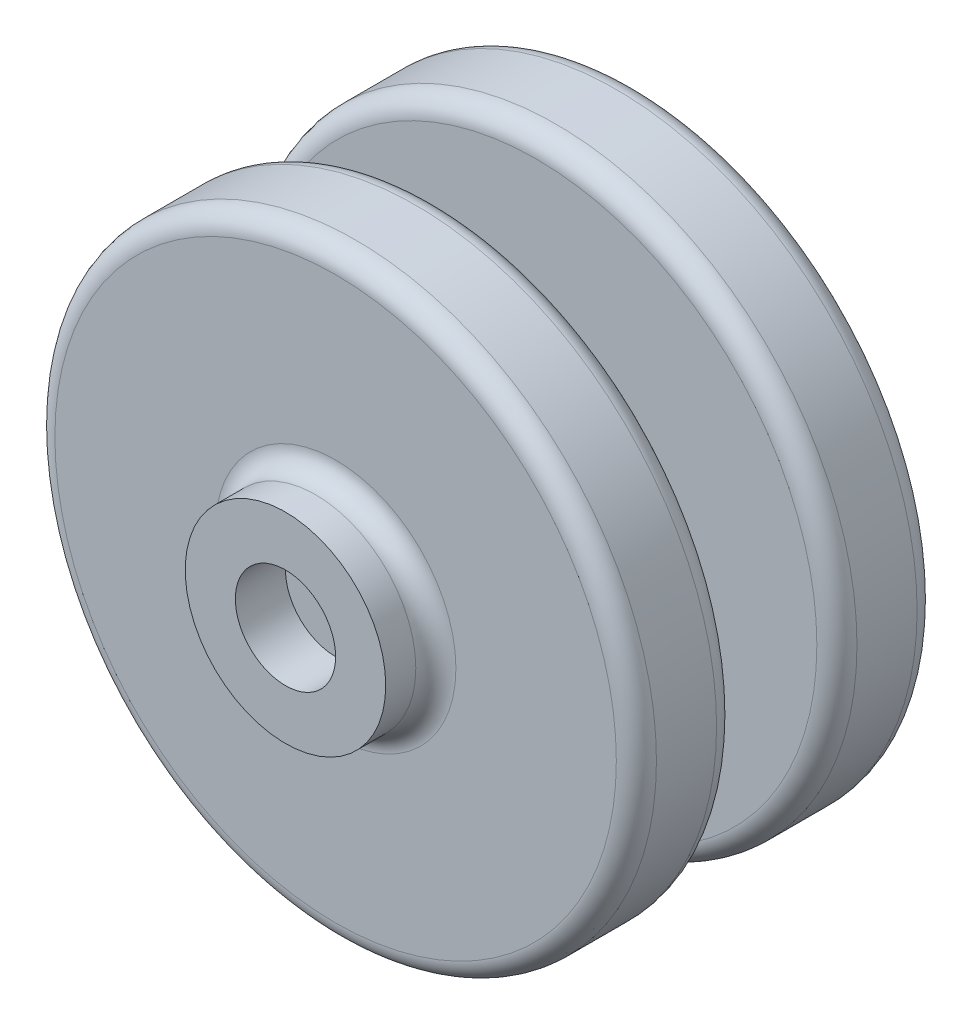
from build123d import *

# Parameters (mm, degrees)
SKETCH1_R           = 30
BOSS_EXTRUDE1_DEPTH = 10
SKETCH2_R           = 5
BOSS_EXTRUDE2_DEPTH = 10
SKETCH3_R           = 30
BOSS_EXTRUDE3_DEPTH = 10
SKETCH5_R           = 10
SKETCH5_R_2         = 5
BOSS_EXTRUDE5_DEPTH = 5
FILLET1_R           = 2
FILLET2_R           = 2


with BuildPart() as part:
    # Sketch1 → Boss-Extrude1 (new body)
    with BuildSketch(Plane.XY):
        Circle(SKETCH1_R)
    extrude(amount=BOSS_EXTRUDE1_DEPTH)

    # Sketch2 → Boss-Extrude2 (add)
    with BuildSketch(Plane.XY.offset(10)):
        Circle(SKETCH2_R)
    extrude(amount=BOSS_EXTRUDE2_DEPTH)

    # Sketch3 → Boss-Extrude3 (add)
    with BuildSketch(Plane.XY.offset(20)):
        Circle(SKETCH3_R)
    extrude(amount=BOSS_EXTRUDE3_DEPTH)

    # Sketch5 → Boss-Extrude5 (add)
    with BuildSketch(Plane.XY.offset(30)):
        Circle(SKETCH5_R)
        Circle(SKETCH5_R_2, mode=Mode.SUBTRACT)
    boss_extrude5 = extrude(amount=BOSS_EXTRUDE5_DEPTH)

    # Mirror1: Boss-Extrude5 across plane
    add(boss_extrude5.mirror(Plane.XY.offset(15)))

    # Fillet1
    fillet1_edges = [part.edges().sort_by_distance(p)[0] for p in [
        (-10, 0, 30),
        (-10, 0, 0),
    ]]
    fillet(fillet1_edges, radius=FILLET1_R)

    # Fillet2
    fillet2_edges = [part.edges().sort_by_distance(p)[0] for p in [
        (-30, 0, 30),
        (-30, 0, 0),
        (-30, 0, 10),
        (-30, 0, 20),
    ]]
    fillet(fillet2_edges, radius=FILLET2_R)


solid = part.part
